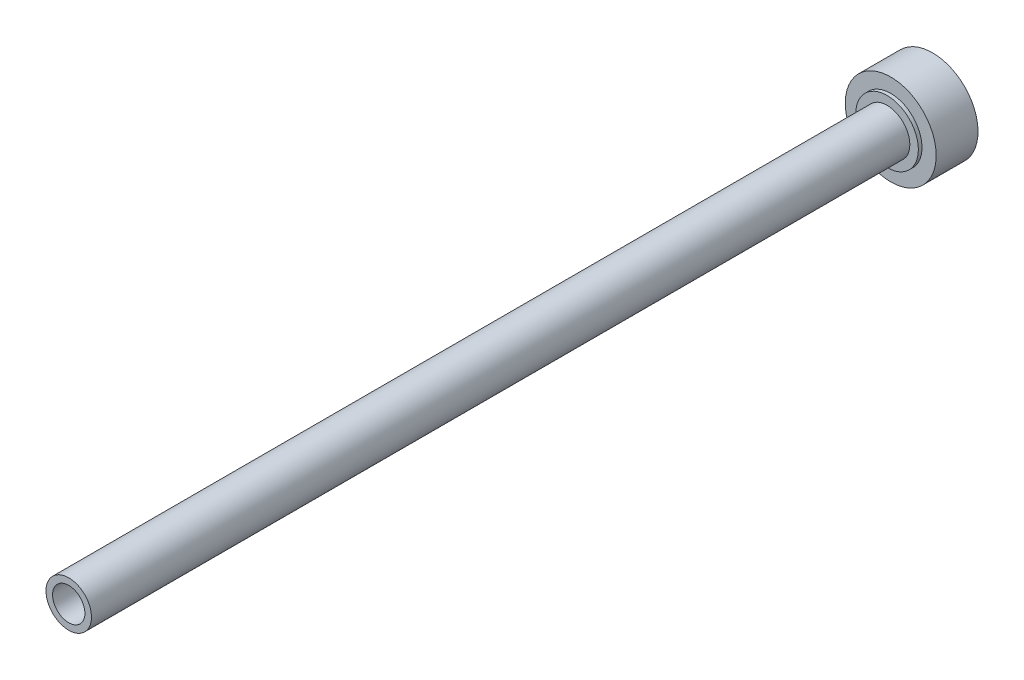
from build123d import *

# Parameters (mm, degrees)
SKETCH1_W                 = 57.15
SKETCH1_H                 = 1.5875
F_4_40_TAPPED_HOLE1_D     = 2.2606
F_4_40_TAPPED_HOLE1_DEPTH = 7.62
F_4_40_TAPPED_HOLE1_TIP   = 0.679152758


with BuildPart() as part:
    # Sketch1 → Revolve1 (revolve)
    with BuildSketch(Plane(origin=(0, 0, 0), x_dir=(0, 0, -1), z_dir=(1, 0, 0))):
        with Locations((0, 0.79375)):
            Rectangle(SKETCH1_W, SKETCH1_H)
        Polygon((31.75, 0), (28.575, 0), (28.575, 1.5875), (28.575, 2.1828125), (28.829, 2.1828125), (28.829, 3.175), (31.75, 3.175), align=None)
    revolve(axis=Axis((0, 0, 28.575), (0, 0, -1)))

    # #4-40 Tapped Hole1
    with Locations(Plane.XY.offset(28.575)):
        with Locations((0, 0)):
            Hole(F_4_40_TAPPED_HOLE1_D / 2, depth=F_4_40_TAPPED_HOLE1_DEPTH)
            with Locations((0, 0, -(F_4_40_TAPPED_HOLE1_DEPTH + F_4_40_TAPPED_HOLE1_TIP / 2))):  # 118° drill point
                Cone(0, F_4_40_TAPPED_HOLE1_D / 2, F_4_40_TAPPED_HOLE1_TIP, mode=Mode.SUBTRACT)


solid = part.part
